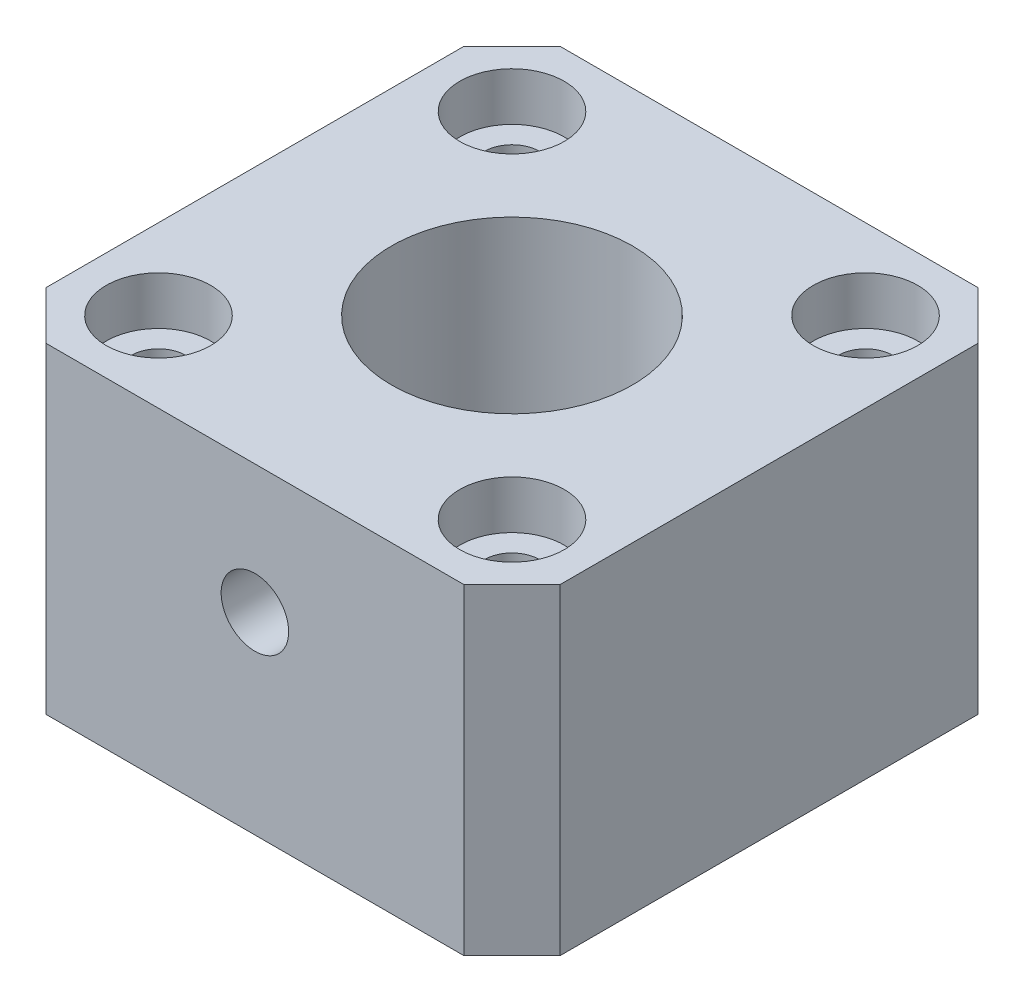
from build123d import *

# Parameters (mm, degrees)
SKETCH1_W                      = 32
SKETCH1_H                      = 32
SKETCH1_R                      = 7.5
BOSS_EXTRUDE1_DEPTH            = 20
CBORE_FOR_M3_SHCS1_D           = 3.4
CBORE_FOR_M3_SHCS1_CBORE_D     = 6.5
CBORE_FOR_M3_SHCS1_CBORE_DEPTH = 3
M5X0_8_TAPPED_HOLE1_REACH      = 42.988
M5X0_8_TAPPED_HOLE1_BORE_R     = 2.1
CHAMFER1_SIZE                  = 3


with BuildPart() as part:
    # Sketch1 → Boss-Extrude1 (new body)
    with BuildSketch(Plane(origin=(0, 0, 0), x_dir=(1, 0, 0), z_dir=(0, 1, 0))):
        Rectangle(SKETCH1_W, SKETCH1_H)
        with Locations(Location((0, 0, 0), (0, 0, 270))):
            Circle(SKETCH1_R, mode=Mode.SUBTRACT)
    extrude(amount=BOSS_EXTRUDE1_DEPTH)

    # CBORE for M3 SHCS1 (through all)
    with Locations(Plane(origin=(0, 20, 0), x_dir=(1, 0, 0), z_dir=(0, 1, 0))):
        with Locations((-11, 11), (11, 11), (11, -11), (-11, -11)):
            CounterBoreHole(CBORE_FOR_M3_SHCS1_D / 2, CBORE_FOR_M3_SHCS1_CBORE_D / 2, CBORE_FOR_M3_SHCS1_CBORE_DEPTH)

    # M5x0.8 Tapped Hole1 bore → M5x0.8 Tapped Hole1 (cut, up to next)
    with BuildSketch(Plane.XY.offset(16), mode=Mode.PRIVATE) as m5x0_8_tapped_hole1_sk1:
        with Locations((0, 12)):
            Circle(M5X0_8_TAPPED_HOLE1_BORE_R)
    m5x0_8_tapped_hole1_tool1 = extrude(m5x0_8_tapped_hole1_sk1.sketch, amount=-M5X0_8_TAPPED_HOLE1_REACH, mode=Mode.PRIVATE) & part.part
    add(m5x0_8_tapped_hole1_tool1.solids().sort_by_distance((0, 12, 16))[0], mode=Mode.SUBTRACT)

    # Chamfer1
    chamfer1_edges = [part.edges().sort_by_distance(p)[0] for p in [
        (-16, 10, -16),
        (16, 10, -16),
        (16, 10, 16),
        (-16, 10, 16),
    ]]
    chamfer(chamfer1_edges, length=CHAMFER1_SIZE)


solid = part.part
